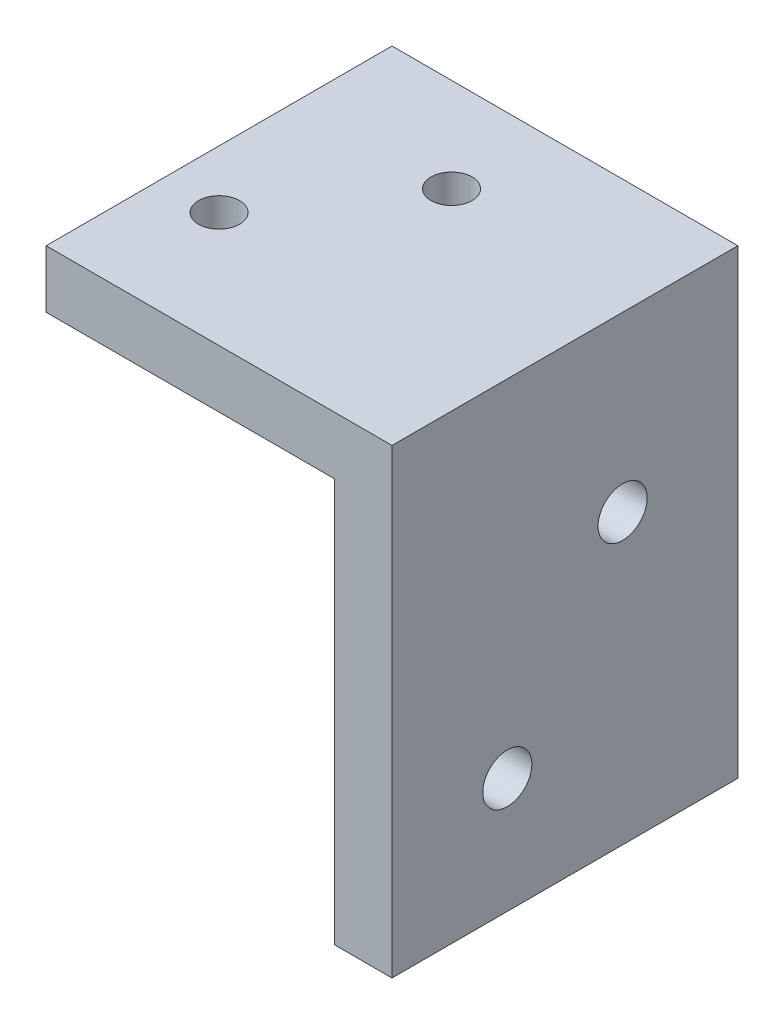
from build123d import *

# Parameters (mm, degrees)
BOSS_EXTRUDE1_DEPTH           = 6.35
BOSS_EXTRUDE1_DEPTH_BACK      = 12.7
TAP_DRILL_FOR_6_32_TAP1_D     = 2.7051
TAP_DRILL_FOR_4_40_TAP1_D     = 2.2606
TAP_DRILL_FOR_4_40_TAP1_DEPTH = 3.302
TAP_DRILL_FOR_4_40_TAP1_TIP   = 0.679152758


with BuildPart() as part:
    # Sketch1 → Boss-Extrude1 (new body, two sides)
    with BuildSketch(Plane.XY) as boss_extrude1_sk:
        Polygon((-59.907074584, 30.83161157), (-40.857074584, 30.83161157), (-40.857074584, 5.43161157), (-44.032074584, 5.43161157), (-44.032074584, 27.65661157), (-59.907074584, 27.65661157), align=None)
    extrude(amount=BOSS_EXTRUDE1_DEPTH)
    extrude(boss_extrude1_sk.sketch, amount=-BOSS_EXTRUDE1_DEPTH_BACK)

    # Tap Drill for #6-32 Tap1 (through all)
    with Locations(Plane(origin=(-44.032074584, 11.78161157, 0), x_dir=(0, 0, -1), z_dir=(-1, 0, 0))):
        with Locations((0, 0), (6.35, -9.525)):
            Hole(TAP_DRILL_FOR_6_32_TAP1_D / 2)

    # Tap Drill for #4-40 Tap1
    with Locations(Plane(origin=(-51.458153967, 30.83161157, -7.531939217), x_dir=(0, 0, 1), z_dir=(0, 1, 0))):
        with Locations((0, 0), (7.531939217, -5.273920617)):
            Hole(TAP_DRILL_FOR_4_40_TAP1_D / 2, depth=TAP_DRILL_FOR_4_40_TAP1_DEPTH)
            with Locations((0, 0, -(TAP_DRILL_FOR_4_40_TAP1_DEPTH + TAP_DRILL_FOR_4_40_TAP1_TIP / 2))):  # 118° drill point
                Cone(0, TAP_DRILL_FOR_4_40_TAP1_D / 2, TAP_DRILL_FOR_4_40_TAP1_TIP, mode=Mode.SUBTRACT)


solid = part.part
